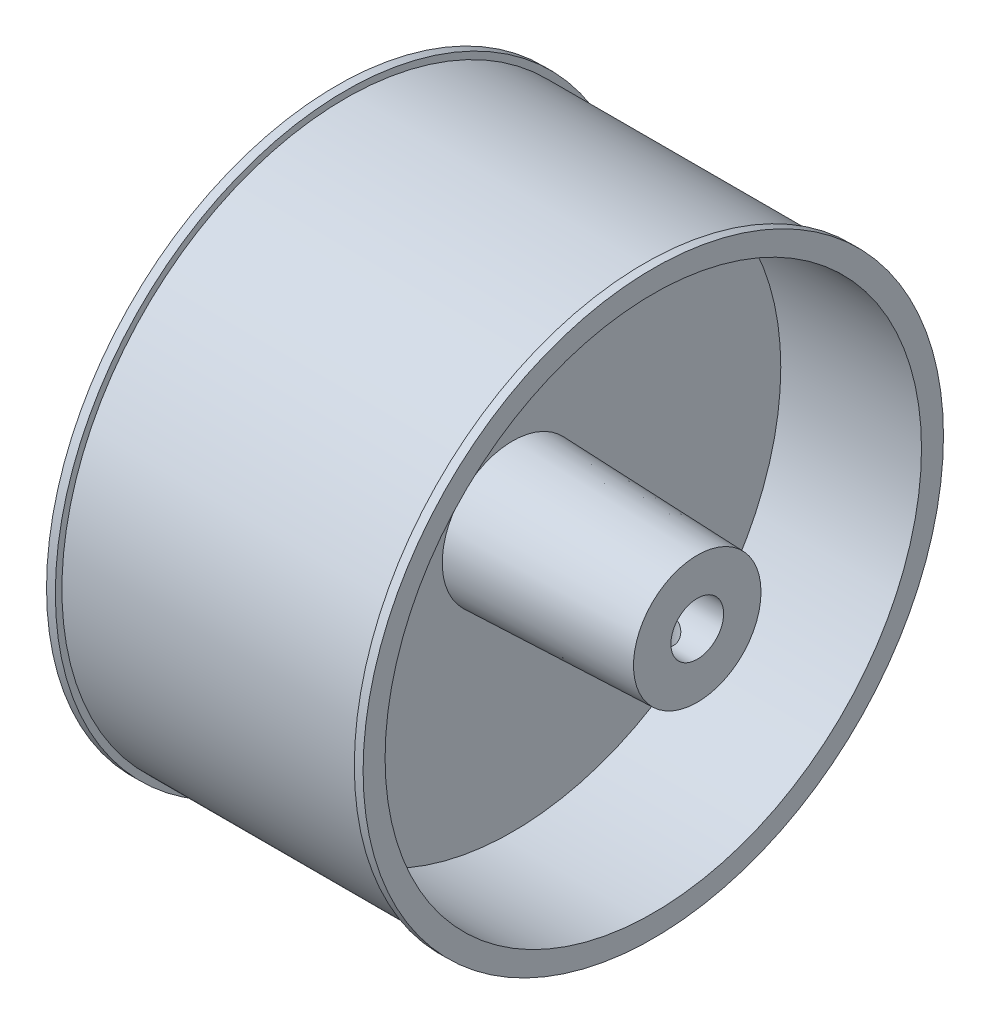
from build123d import *

# Parameters (mm, degrees)
SKETCH1_R               = 33
BOSS_EXTRUDE1_DEPTH     = 36
SKETCH2_R               = 30.5
SKETCH2_R_2             = 8
SKETCH2_R_3             = 3
CUT_EXTRUDE2_DEPTH      = 16
SKETCH6_R               = 7.25
SKETCH5_R               = 8
SKETCH7_R               = 30.5
CUT_EXTRUDE3_DEPTH      = 18
SKETCH8_R               = 3
CUT_EXTRUDE4_DEPTH      = 77
SKETCH9_R               = 42.905856896
SKETCH9_R_2             = 32.25
CUT_EXTRUDE5_DEPTH      = 17
CUT_EXTRUDE5_DEPTH_BACK = 17
SKETCH10_R              = 2
CUT_EXTRUDE6_DEPTH      = 17


with BuildPart() as part:
    # Sketch1 → Boss-Extrude1 (new body)
    with BuildSketch(Plane(origin=(0, 0, 0), x_dir=(0, 0, -1), z_dir=(1, 0, 0))):
        Circle(SKETCH1_R)
    extrude(amount=BOSS_EXTRUDE1_DEPTH)

    # Sketch2 → Cut-Extrude2 (cut)
    with BuildSketch(Plane(origin=(36, 0, 0), x_dir=(0, 0, -1), z_dir=(1, 0, 0))):
        Circle(SKETCH2_R)
        Circle(SKETCH2_R_2, mode=Mode.SUBTRACT)
        Circle(SKETCH2_R_2)
        Circle(SKETCH2_R_3, mode=Mode.SUBTRACT)
        Circle(SKETCH2_R_3)
    extrude(amount=-CUT_EXTRUDE2_DEPTH, mode=Mode.SUBTRACT)

    # Sketch6 → Loft2 section 0
    with BuildSketch(Plane(origin=(41, 0, 0), x_dir=(0, 0, -1), z_dir=(1, 0, 0))):
        Circle(SKETCH6_R)
    # Sketch5 → Loft2 section 1
    with BuildSketch(Plane(origin=(20, 0, 0), x_dir=(0, 0, -1), z_dir=(1, 0, 0))):
        Circle(SKETCH5_R)
    loft()

    # Sketch7 → Cut-Extrude3 (cut)
    with BuildSketch(Plane.ZY):
        with Locations(Location((0, 0, 0), (0, 0, 180))):
            Circle(SKETCH7_R)
    extrude(amount=-CUT_EXTRUDE3_DEPTH, mode=Mode.SUBTRACT)

    # Sketch8 → Cut-Extrude4 (cut)
    with BuildSketch(Plane(origin=(41, 0, 0), x_dir=(0, 0, -1), z_dir=(1, 0, 0))):
        Circle(SKETCH8_R)
    extrude(amount=-CUT_EXTRUDE4_DEPTH, mode=Mode.SUBTRACT)

    # Sketch9 → Cut-Extrude5 (cut, two sides)
    with BuildSketch(Plane(origin=(18, 0, 0), x_dir=(0, 0, -1), z_dir=(1, 0, 0))) as cut_extrude5_sk:
        Circle(SKETCH9_R)
        Circle(SKETCH9_R_2, mode=Mode.SUBTRACT)
    extrude(amount=CUT_EXTRUDE5_DEPTH, mode=Mode.SUBTRACT)
    extrude(cut_extrude5_sk.sketch, amount=-CUT_EXTRUDE5_DEPTH_BACK, mode=Mode.SUBTRACT)

    # Sketch10 → Cut-Extrude6 (cut)
    with BuildSketch(Plane(origin=(0, 0, 0), x_dir=(1, 0, 0), z_dir=(0, 1, 0))):
        with Locations(Location((36.300187477, 0, 0), (0, 0, 270))):
            Circle(SKETCH10_R)
    extrude(amount=-CUT_EXTRUDE6_DEPTH, mode=Mode.SUBTRACT)


solid = part.part
